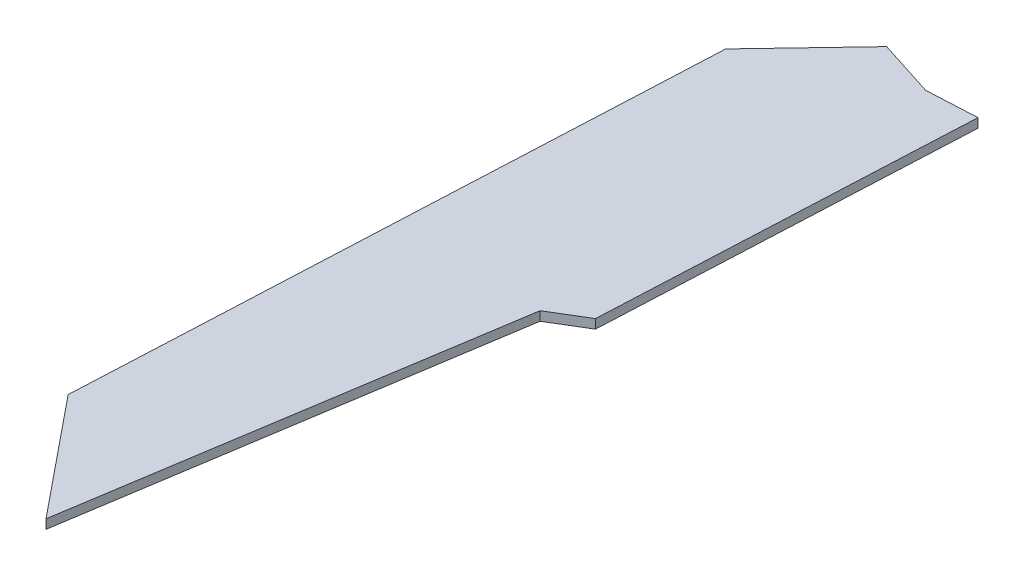
from build123d import *

# Parameters (mm, degrees)
BOSS_EXTRU_1_DEPTH = 2


with BuildPart() as part:
    # Esquisse1 → Boss.-Extru.1 (new body)
    with BuildSketch(Plane(origin=(0, 0, 0), x_dir=(1, 0, 0), z_dir=(0, 1, 0))):
        Polygon((46.905771836, 151.526469081), (36.038044595, 150.978520449), (23.538196974, 154.984684673), (6.420162087, 136.985002161), (0, 0), (21.042979561, -25.869393476), (35.615674602, 67.312043067), (43.146378805, 71.865563651), align=None)
    extrude(amount=BOSS_EXTRU_1_DEPTH)


solid = part.part
